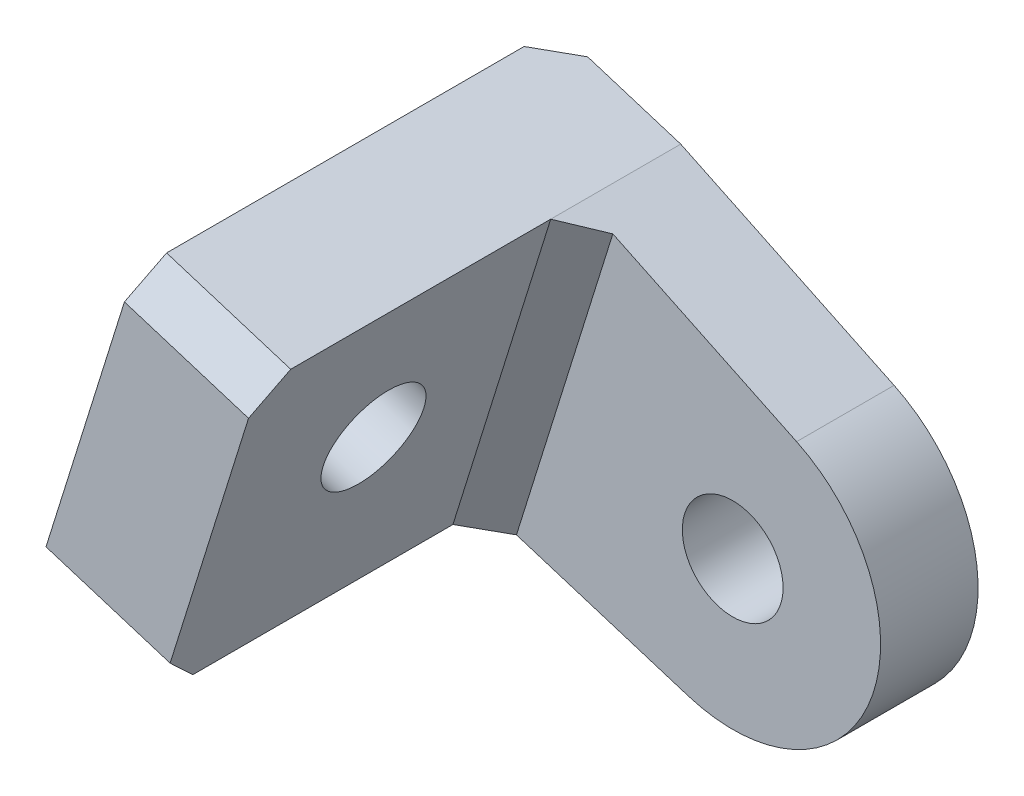
from build123d import *

# Parameters (mm, degrees)
SKETCH1_R           = 1.55
BOSS_EXTRUDE1_DEPTH = 3
BOSS_EXTRUDE2_DEPTH = 10
CUT_EXTRUDE1_REACH  = 18.249
SKETCH3_RX          = 1.55
SKETCH3_RY          = 1.549991194
CHAMFER1_SIZE       = 1
CHAMFER2_SIZE       = 1
CHAMFER3_SIZE       = 1


with BuildPart() as part:
    # Sketch1 → Boss-Extrude1 (new body)
    with BuildSketch(Plane.XY):
        with BuildLine():
            Line((9.241088209, 28.022032198), (2.675653796, 31.16807272))
            Line((2.675653796, 31.16807272), (-1.142729479, 32.359688918))
            Line((-1.142729479, 32.359688918), (-4.151560379, 22.718271148))
            Line((-4.151560379, 22.718271148), (5.91942551, 19.575383426))
            ThreePointArc((5.91942551, 19.575383426), (11.509238759, 22.253627274), (9.241088209, 28.022032198))
        make_face()
        with Locations((7.274888935, 23.918794401)):
            Circle(SKETCH1_R, mode=Mode.SUBTRACT)
    extrude(amount=BOSS_EXTRUDE1_DEPTH)

    # Sketch2 → Boss-Extrude2 (add)
    with BuildSketch(Plane.XY.offset(3)):
        Polygon((-1.142729479, 32.359688918), (-4.151560379, 22.718271148), (-0.333177104, 21.52665495), (2.675653796, 31.16807272), align=None)
    extrude(amount=BOSS_EXTRUDE2_DEPTH)

    # Sketch3 → Cut-Extrude1 (cut, up to next)
    with BuildSketch(Plane(origin=(-10.243698191, 3.196786653, 0), x_dir=(0, 0, 1), z_dir=(-0.954595819, 0.297904049, 0)), mode=Mode.PRIVATE) as cut_extrude1_sk1:
        with Locations(Location((8.05588909, 25.857711156), (0, 0, -179.999999999))):
            Ellipse(SKETCH3_RX, SKETCH3_RY)
    cut_extrude1_tool1 = extrude(cut_extrude1_sk1.sketch, amount=-CUT_EXTRUDE1_REACH, mode=Mode.PRIVATE) & part.part
    add(cut_extrude1_tool1.solids().sort_by_distance((-2.540581, 27.88045, 8.055889))[0], mode=Mode.SUBTRACT)

    # Chamfer1
    chamfer1_edges = [part.edges().sort_by_distance(p)[0] for p in [
        (-2.242368741, 22.122463049, 13),
        (0.766462159, 31.763880819, 13),
    ]]
    chamfer(chamfer1_edges, length=CHAMFER1_SIZE)

    # Chamfer2
    chamfer2_edges = [part.edges().sort_by_distance(p)[0] for p in [
        (1.171238346, 26.347363835, 3),
    ]]
    chamfer(chamfer2_edges, length=CHAMFER2_SIZE)

    # Chamfer3
    chamfer3_edges = [part.edges().sort_by_distance(p)[0] for p in [
        (-2.647144929, 27.538980033, 0),
    ]]
    chamfer(chamfer3_edges, length=CHAMFER3_SIZE)


solid = part.part
